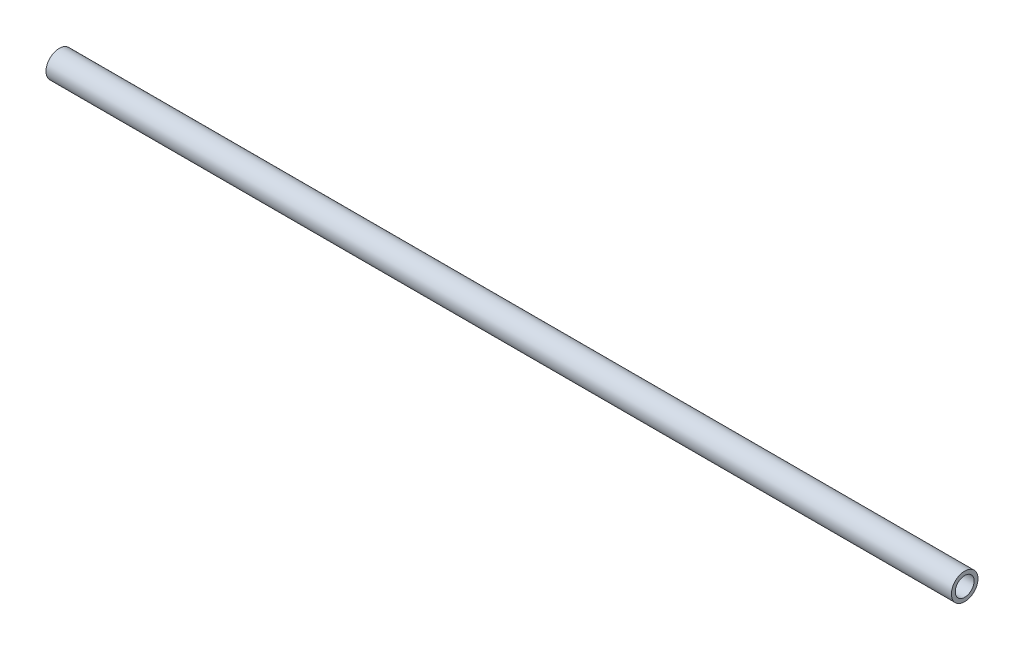
from build123d import *

# Parameters (mm, degrees)
BOSS_EXTRUDE1_DEPTH      = 304.8
BOSS_EXTRUDE1_DEPTH_BACK = 304.8
SKETCH1_R                = 8.9535
SKETCH1_R_2              = 6.35


with BuildPart() as part:
    # Sketch1 → Boss-Extrude1 (new, two sides: drawn at the far end of the back side and taken through both)
    with BuildSketch(Plane(origin=(0, 0, 0), x_dir=(0, 0, -1), z_dir=(1, 0, 0)).offset(-BOSS_EXTRUDE1_DEPTH_BACK)):
        Circle(SKETCH1_R)
        Circle(SKETCH1_R_2, mode=Mode.SUBTRACT)
    extrude(amount=BOSS_EXTRUDE1_DEPTH + BOSS_EXTRUDE1_DEPTH_BACK)


solid = part.part
